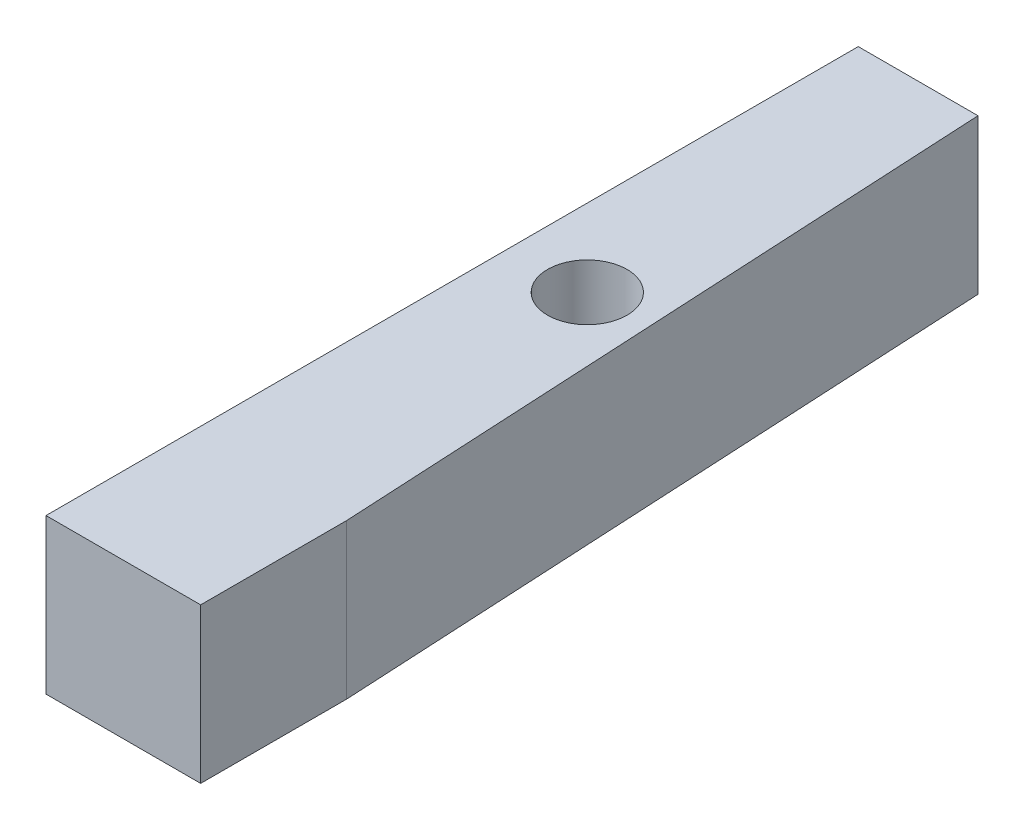
from build123d import *

# Parameters (mm, degrees)
SKETCH1_W           = 25.4
SKETCH1_H           = 25.4
BOSS_EXTRUDE1_DEPTH = 133.4008
SKETCH2_R           = 6.524301876
CUT_EXTRUDE2_DEPTH  = 26.4
CUT_EXTRUDE3_DEPTH  = 26.4


with BuildPart() as part:
    # Sketch1 → Boss-Extrude1 (new body)
    with BuildSketch(Plane.XY):
        Rectangle(SKETCH1_W, SKETCH1_H)
    extrude(amount=-BOSS_EXTRUDE1_DEPTH)

    # Sketch2 → Cut-Extrude2 (cut, through all)
    with BuildSketch(Plane(origin=(0, 12.7, 0), x_dir=(1, 0, 0), z_dir=(0, 1, 0))):
        with Locations((0, 76.2)):
            Circle(SKETCH2_R)
    extrude(amount=-CUT_EXTRUDE2_DEPTH, mode=Mode.SUBTRACT)

    # Sketch3 → Cut-Extrude3 (cut, through all)
    with BuildSketch(Plane(origin=(0, 12.7, 0), x_dir=(1, 0, 0), z_dir=(0, 1, 0))):
        Polygon((12.7, 133.4008), (6.96541308, 133.4008), (12.7, 23.978363128), align=None)
    extrude(amount=-CUT_EXTRUDE3_DEPTH, mode=Mode.SUBTRACT)


solid = part.part
